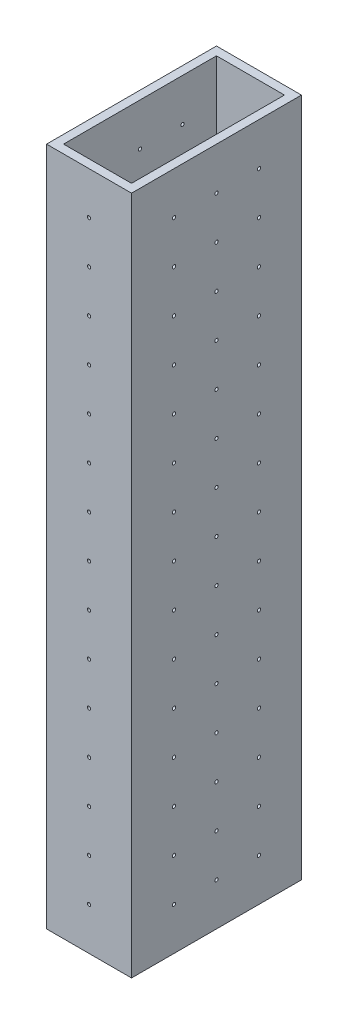
from build123d import *

# Parameters (mm, degrees)
SKETCH1_W           = 25.4
SKETCH1_H           = 50.8
SKETCH1_W_2         = 20.32
SKETCH1_H_2         = 45.72
BOSS_EXTRUDE1_DEPTH = 203.2
SKETCH2_R           = 0.5
CUT_EXTRUDE1_DEPTH  = 50.8
SKETCH3_R           = 0.5
CUT_EXTRUDE2_DEPTH  = 25.4


with BuildPart() as part:
    # Sketch1 → Boss-Extrude1 (new body)
    with BuildSketch(Plane(origin=(0, 0, 0), x_dir=(1, 0, 0), z_dir=(0, 1, 0))):
        with Locations((7.218947368, -16.142368421)):
            Rectangle(SKETCH1_W, SKETCH1_H)
        with Locations((7.218947368, -16.142368421)):
            Rectangle(SKETCH1_W_2, SKETCH1_H_2, mode=Mode.SUBTRACT)
    extrude(amount=BOSS_EXTRUDE1_DEPTH)

    # Sketch2 → Cut-Extrude1 (cut)
    with BuildSketch(Plane(origin=(0, 0, -9.257631579), x_dir=(-1, 0, 0), z_dir=(0, 0, -1))):
        with Locations((-7.218947368, 190.5)):
            Circle(SKETCH2_R)
        with Locations((-7.218947368, 177.8)):
            Circle(SKETCH2_R)
        with Locations((-7.218947368, 165.1)):
            Circle(SKETCH2_R)
        with Locations((-7.218947368, 152.4)):
            Circle(SKETCH2_R)
        with Locations((-7.218947368, 139.7)):
            Circle(SKETCH2_R)
        with Locations((-7.218947368, 127)):
            Circle(SKETCH2_R)
        with Locations((-7.218947368, 114.3)):
            Circle(SKETCH2_R)
        with Locations((-7.218947368, 101.6)):
            Circle(SKETCH2_R)
        with Locations((-7.218947368, 88.9)):
            Circle(SKETCH2_R)
        with Locations((-7.218947368, 76.2)):
            Circle(SKETCH2_R)
        with Locations((-7.218947368, 63.5)):
            Circle(SKETCH2_R)
        with Locations((-7.218947368, 50.8)):
            Circle(SKETCH2_R)
        with Locations((-7.218947368, 38.1)):
            Circle(SKETCH2_R)
        with Locations((-7.218947368, 25.4)):
            Circle(SKETCH2_R)
        with Locations((-7.218947368, 12.7)):
            Circle(SKETCH2_R)
    extrude(amount=-CUT_EXTRUDE1_DEPTH, mode=Mode.SUBTRACT)

    # Sketch3 → Cut-Extrude2 (cut)
    with BuildSketch(Plane(origin=(19.918947368, 0, 0), x_dir=(0, 0, -1), z_dir=(1, 0, 0))):
        with Locations((-3.442368421, 190.5)):
            Circle(SKETCH3_R)
        with Locations((-16.142368421, 190.5)):
            Circle(SKETCH3_R)
        with Locations((-28.842368421, 190.5)):
            Circle(SKETCH3_R)
        with Locations((-16.142368421, 177.8)):
            Circle(SKETCH3_R)
        with Locations((-28.842368421, 177.8)):
            Circle(SKETCH3_R)
        with Locations((-16.142368421, 165.1)):
            Circle(SKETCH3_R)
        with Locations((-28.842368421, 165.1)):
            Circle(SKETCH3_R)
        with Locations((-16.142368421, 152.4)):
            Circle(SKETCH3_R)
        with Locations((-28.842368421, 152.4)):
            Circle(SKETCH3_R)
        with Locations((-16.142368421, 139.7)):
            Circle(SKETCH3_R)
        with Locations((-28.842368421, 139.7)):
            Circle(SKETCH3_R)
        with Locations((-16.142368421, 127)):
            Circle(SKETCH3_R)
        with Locations((-28.842368421, 127)):
            Circle(SKETCH3_R)
        with Locations((-16.142368421, 114.3)):
            Circle(SKETCH3_R)
        with Locations((-28.842368421, 114.3)):
            Circle(SKETCH3_R)
        with Locations((-16.142368421, 101.6)):
            Circle(SKETCH3_R)
        with Locations((-28.842368421, 101.6)):
            Circle(SKETCH3_R)
        with Locations((-16.142368421, 88.9)):
            Circle(SKETCH3_R)
        with Locations((-28.842368421, 88.9)):
            Circle(SKETCH3_R)
        with Locations((-16.142368421, 76.2)):
            Circle(SKETCH3_R)
        with Locations((-28.842368421, 76.2)):
            Circle(SKETCH3_R)
        with Locations((-16.142368421, 63.5)):
            Circle(SKETCH3_R)
        with Locations((-28.842368421, 63.5)):
            Circle(SKETCH3_R)
        with Locations((-16.142368421, 50.8)):
            Circle(SKETCH3_R)
        with Locations((-28.842368421, 50.8)):
            Circle(SKETCH3_R)
        with Locations((-16.142368421, 38.1)):
            Circle(SKETCH3_R)
        with Locations((-28.842368421, 38.1)):
            Circle(SKETCH3_R)
        with Locations((-3.442368421, 177.8)):
            Circle(SKETCH3_R)
        with Locations((-3.442368421, 165.1)):
            Circle(SKETCH3_R)
        with Locations((-3.442368421, 152.4)):
            Circle(SKETCH3_R)
        with Locations((-3.442368421, 139.7)):
            Circle(SKETCH3_R)
        with Locations((-3.442368421, 127)):
            Circle(SKETCH3_R)
        with Locations((-3.442368421, 114.3)):
            Circle(SKETCH3_R)
        with Locations((-3.442368421, 101.6)):
            Circle(SKETCH3_R)
        with Locations((-3.442368421, 88.9)):
            Circle(SKETCH3_R)
        with Locations((-3.442368421, 76.2)):
            Circle(SKETCH3_R)
        with Locations((-3.442368421, 63.5)):
            Circle(SKETCH3_R)
        with Locations((-3.442368421, 50.8)):
            Circle(SKETCH3_R)
        with Locations((-3.442368421, 38.1)):
            Circle(SKETCH3_R)
        with Locations((-3.442368421, 25.4)):
            Circle(SKETCH3_R)
        with Locations((-16.142368421, 25.4)):
            Circle(SKETCH3_R)
        with Locations((-28.842368421, 25.4)):
            Circle(SKETCH3_R)
        with Locations((-3.442368421, 12.7)):
            Circle(SKETCH3_R)
        with Locations((-16.142368421, 12.7)):
            Circle(SKETCH3_R)
        with Locations((-28.842368421, 12.7)):
            Circle(SKETCH3_R)
    extrude(amount=-CUT_EXTRUDE2_DEPTH, mode=Mode.SUBTRACT)


solid = part.part
